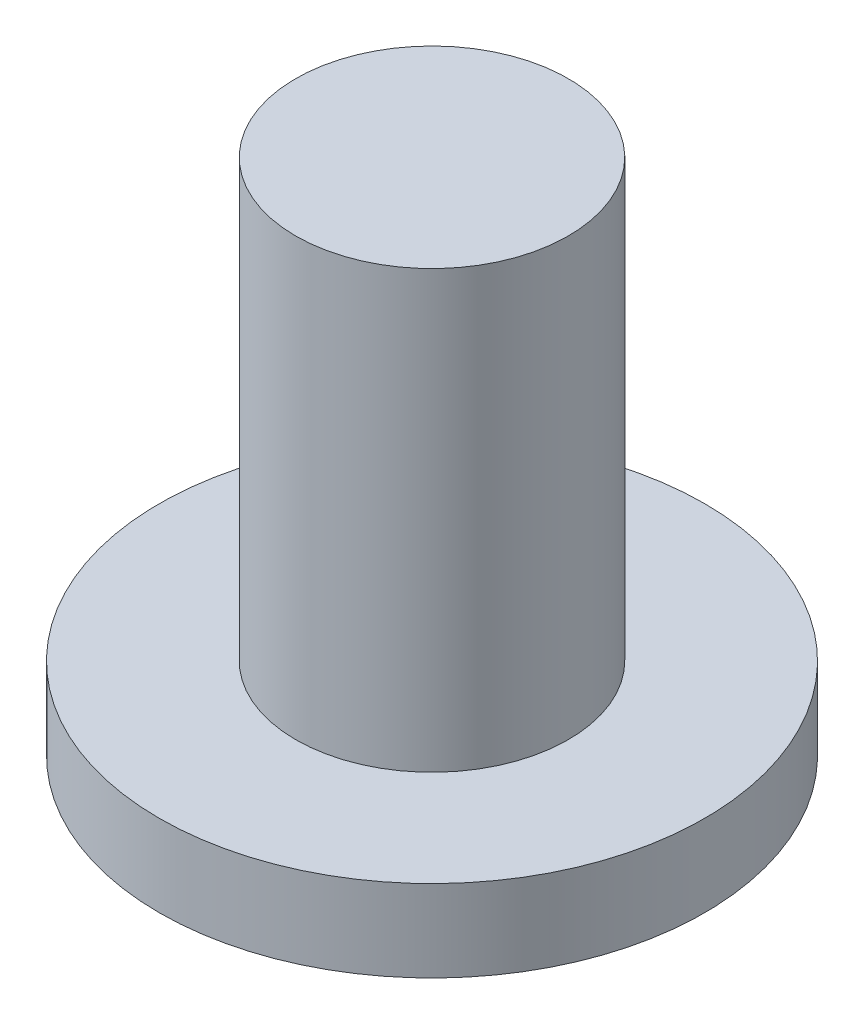
from build123d import *

# Parameters (mm, degrees)
SKETCH_1_R      = 10
EXTRUDE_1_DEPTH = 3
SKETCH_3_R      = 5
EXTRUDE_2_DEPTH = 16


with BuildPart() as part:
    # 草图1 → 凸台-拉伸1 (new body)
    with BuildSketch(Plane(origin=(0, 0, 0), x_dir=(1, 0, 0), z_dir=(0, 1, 0))):
        Circle(SKETCH_1_R)
    extrude(amount=EXTRUDE_1_DEPTH)

    # 草图3 → 凸台-拉伸2 (add)
    with BuildSketch(Plane(origin=(0, 3, 0), x_dir=(1, 0, 0), z_dir=(0, 1, 0))):
        Circle(SKETCH_3_R)
    extrude(amount=EXTRUDE_2_DEPTH)


solid = part.part
